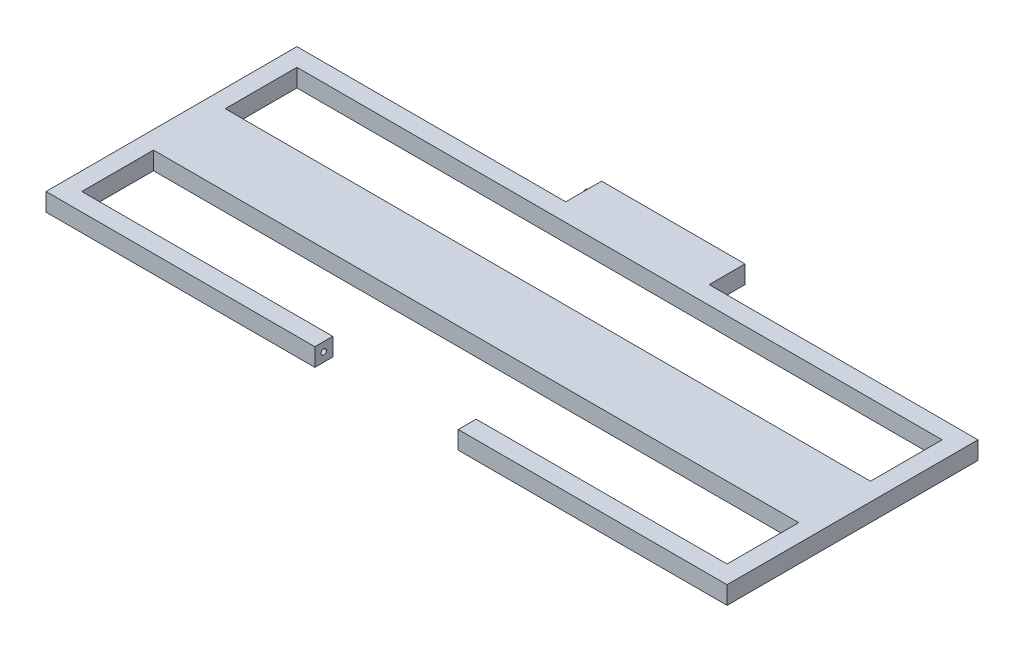
from build123d import *

# Parameters (mm, degrees)
CROQUIS1_W              = 900
CROQUIS1_H              = 100
CROQUIS1_H_2            = 300
CROQUIS1_H_3            = 150
SALIENTE_EXTRUIR2_DEPTH = 25
CORTAR_EXTRUIR1_DEPTH   = 10
CROQUIS3_W              = 950
CROQUIS3_H              = 25
CORTAR_EXTRUIR2_DEPTH   = 850
CROQUIS4_W              = 200
CROQUIS4_H              = 25
SALIENTE_EXTRUIR3_DEPTH = 50
CROQUIS5_R              = 3.75
SALIENTE_EXTRUIR4_DEPTH = 10


with BuildPart() as part:
    # Croquis1 → Saliente-Extruir2 (new body)
    with BuildSketch(Plane(origin=(0, 0, 0), x_dir=(1, 0, 0), z_dir=(0, 1, 0))):
        Polygon((450, -475), (450, -575), (100, -575), (100, -600), (475, -600), (475, 600), (-475, 600), (-475, -600), (-100, -600), (-100, -575), (-450, -575), (-450, -475), align=None)
        with Locations((0, -325)):
            Rectangle(CROQUIS1_W, CROQUIS1_H, mode=Mode.SUBTRACT)
        with Locations((0, -25)):
            Rectangle(CROQUIS1_W, CROQUIS1_H_2, mode=Mode.SUBTRACT)
        with Locations((0, 350)):
            Rectangle(CROQUIS1_W, CROQUIS1_H_3, mode=Mode.SUBTRACT)
    extrude(amount=SALIENTE_EXTRUIR2_DEPTH)

    # Croquis2 → Cortar-Extruir1 (cut)
    with BuildSketch(Plane(origin=(-100, 0, 0), x_dir=(0, 0, -1), z_dir=(1, 0, 0))):
        with BuildLine():
            ThreePointArc((-583.75, 12.5), (-586.064937129, 15.964548247), (-590.151650429, 15.151650429))
            Line((-590.151650429, 15.151650429), (-584.848349571, 9.848349571))
            ThreePointArc((-584.848349571, 9.848349571), (-584.035451753, 11.064937129), (-583.75, 12.5))
        make_face()
        with BuildLine():
            Line((-584.848349571, 9.848349571), (-590.151650429, 15.151650429))
            ThreePointArc((-590.151650429, 15.151650429), (-590.151650429, 9.848349571), (-584.848349571, 9.848349571))
        make_face()
    extrude(amount=-CORTAR_EXTRUIR1_DEPTH, mode=Mode.SUBTRACT)

    # Croquis3 → Cortar-Extruir2 (cut)
    with BuildSketch(Plane(origin=(0, 0, -600), x_dir=(-1, 0, 0), z_dir=(0, 0, -1))):
        with Locations((0, 12.5)):
            Rectangle(CROQUIS3_W, CROQUIS3_H)
    extrude(amount=-CORTAR_EXTRUIR2_DEPTH, mode=Mode.SUBTRACT)

    # Croquis4 → Saliente-Extruir3 (add)
    with BuildSketch(Plane(origin=(0, 0, 250), x_dir=(-1, 0, 0), z_dir=(0, 0, -1))):
        with Locations((0, 12.5)):
            Rectangle(CROQUIS4_W, CROQUIS4_H)
    extrude(amount=SALIENTE_EXTRUIR3_DEPTH)

    # Croquis5 → Saliente-Extruir4 (add)
    with BuildSketch(Plane.ZY.offset(100)):
        with Locations((212.5, 12.5)):
            Circle(CROQUIS5_R)
    extrude(amount=SALIENTE_EXTRUIR4_DEPTH)


solid = part.part
